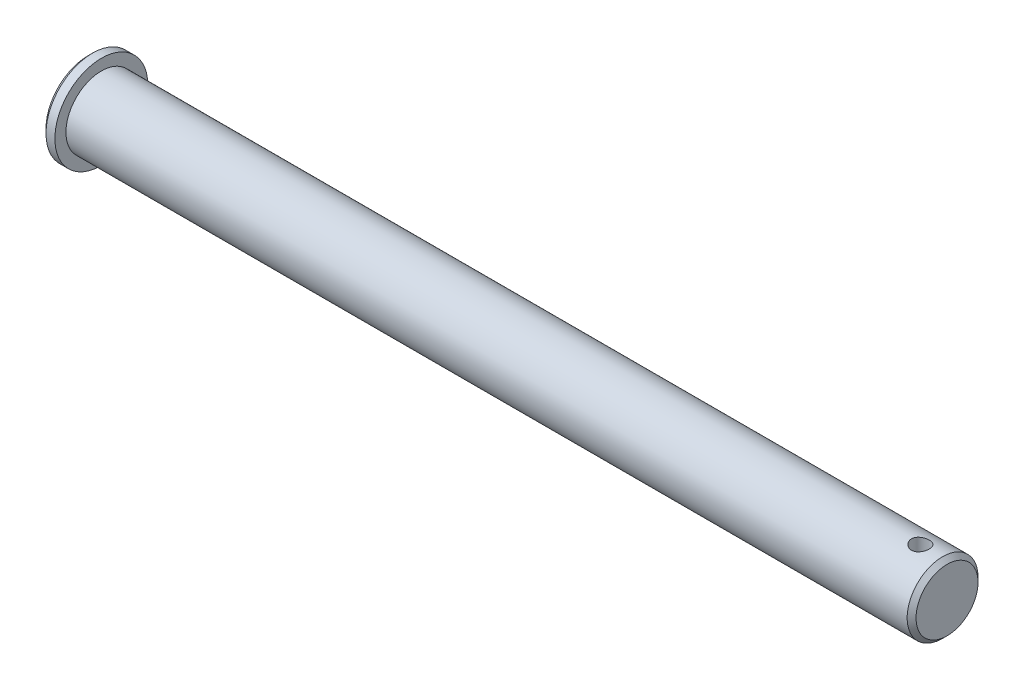
from build123d import *

# Parameters (mm, degrees)
SZKIC2_R                        = 2
WYTNIJ_WYCI_GNI_CIE1_DEPTH      = 11.5
WYTNIJ_WYCI_GNI_CIE1_DEPTH_BACK = 11.5
SFAZOWANIE1_SIZE                = 1


with BuildPart() as part:
    # Szkic1 → Obrót1 (revolve)
    with BuildSketch(Plane.XY):
        Polygon((0, 0), (0, 10.5), (3, 10.5), (3, 8), (194, 8), (194, 0), align=None)
    revolve(axis=Axis((194, 0, 0), (-1, 0, 0)))

    # Szkic2 → Wytnij-wyciągnięcie1 (cut, two sides)
    with BuildSketch(Plane(origin=(0, 0, 0), x_dir=(1, 0, 0), z_dir=(0, 1, 0))) as wytnij_wyci_gni_cie1_sk:
        with Locations((188, 0)):
            Circle(SZKIC2_R)
    extrude(amount=WYTNIJ_WYCI_GNI_CIE1_DEPTH, mode=Mode.SUBTRACT)
    extrude(wytnij_wyci_gni_cie1_sk.sketch, amount=-WYTNIJ_WYCI_GNI_CIE1_DEPTH_BACK, mode=Mode.SUBTRACT)

    # Sfazowanie1
    sfazowanie1_edges = [part.edges().sort_by_distance(p)[0] for p in [
        (194, -8, 0),
        (0, -10.5, 0),
    ]]
    chamfer(sfazowanie1_edges, length=SFAZOWANIE1_SIZE)


solid = part.part
